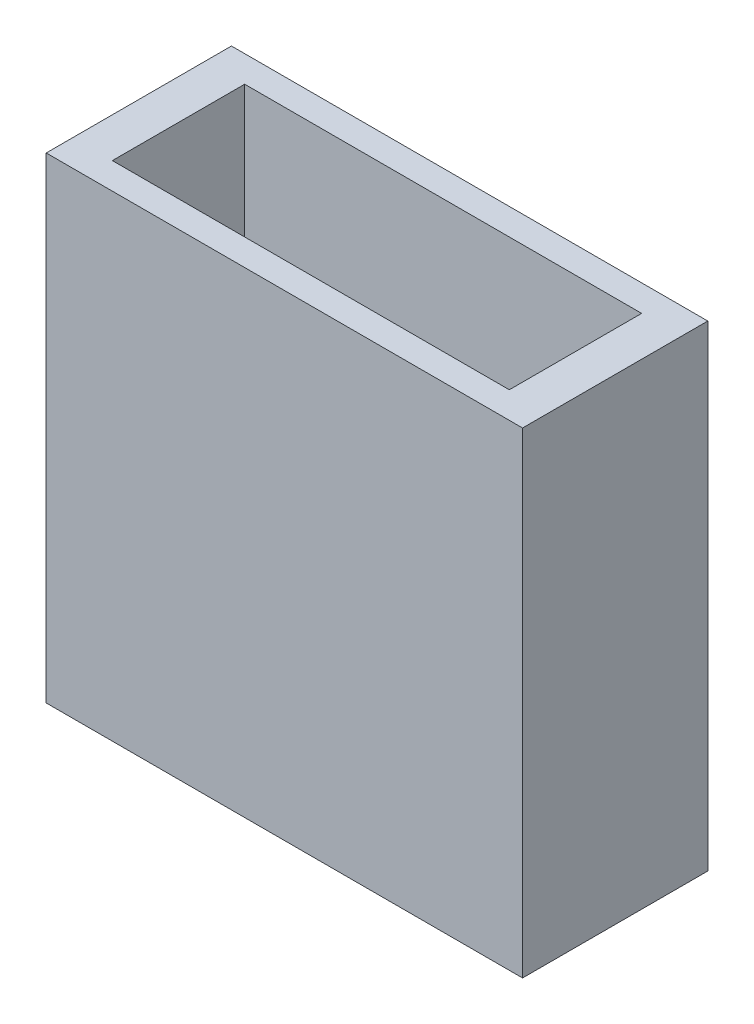
from build123d import *

# Parameters (mm, degrees)
SKETCH1_W           = 45.72
SKETCH1_H           = 17.78
BOSS_EXTRUDE1_DEPTH = 45.72
SKETCH2_W           = 38.1
SKETCH2_H           = 12.7
CUT_EXTRUDE1_DEPTH  = 41.91
SKETCH3_R           = 2.4765
SKETCH3_R_2         = 2.54
CUT_EXTRUDE2_DEPTH  = 46.72


with BuildPart() as part:
    # Sketch1 → Boss-Extrude1 (new body)
    with BuildSketch(Plane(origin=(0, 0, 0), x_dir=(1, 0, 0), z_dir=(0, 1, 0))):
        with Locations((22.86, 8.89)):
            Rectangle(SKETCH1_W, SKETCH1_H)
    extrude(amount=BOSS_EXTRUDE1_DEPTH)

    # Sketch2 → Cut-Extrude1 (cut)
    with BuildSketch(Plane(origin=(0, 45.72, 0), x_dir=(1, 0, 0), z_dir=(0, 1, 0))):
        with Locations((22.86, 8.89)):
            Rectangle(SKETCH2_W, SKETCH2_H)
    extrude(amount=-CUT_EXTRUDE1_DEPTH, mode=Mode.SUBTRACT)

    # Sketch3 → Cut-Extrude2 (cut, through all)
    with BuildSketch(Plane(origin=(0, 0, 0), x_dir=(1, 0, 0), z_dir=(0, 1, 0))):
        with Locations((22.86, 8.89)):
            Circle(SKETCH3_R)
        with Locations((17.018, 8.89)):
            Circle(SKETCH3_R_2)
        with Locations((28.702, 8.89)):
            Circle(SKETCH3_R_2)
    extrude(amount=CUT_EXTRUDE2_DEPTH, mode=Mode.SUBTRACT)


solid = part.part
